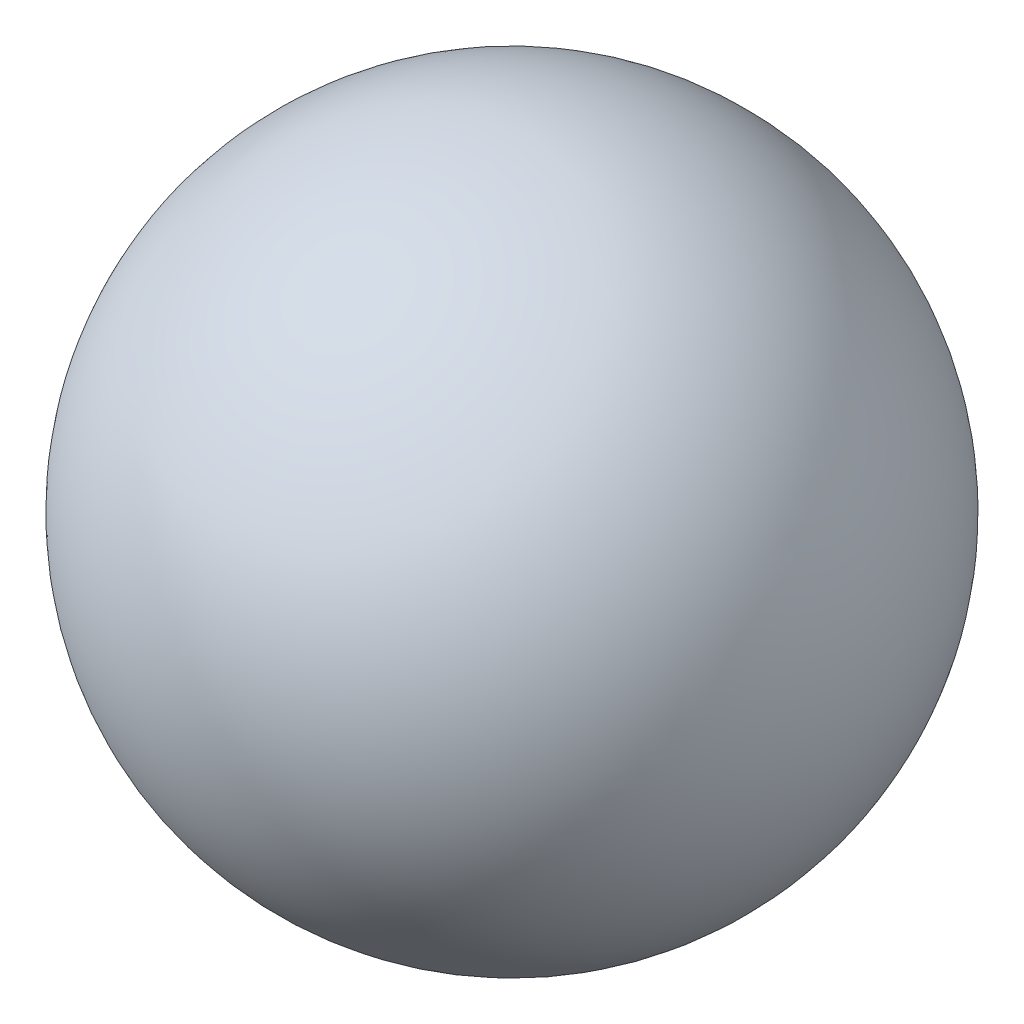
from build123d import *


with BuildPart() as part:
    # Sketch1 → Revolve1 (revolve)
    with BuildSketch(Plane.XY):
        with BuildLine():
            Line((0.45, 0), (-0.45, 0))
            ThreePointArc((-0.45, 0), (0, 0.45), (0.45, 0))
        make_face()
    revolve(axis=Axis((0.45, 0, 0), (-1, 0, 0)))


solid = part.part
